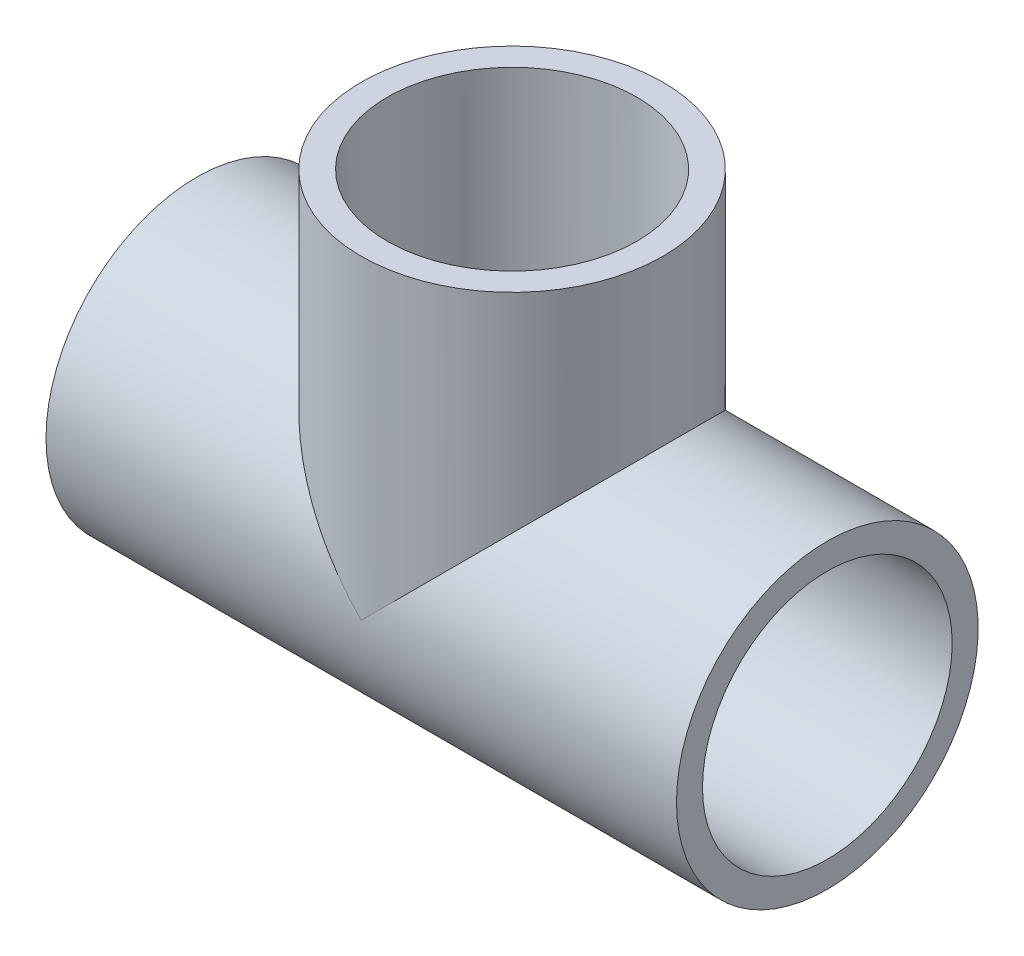
from build123d import *

# Parameters (mm, degrees)
SKETCH4_R           = 20.3327
BOSS_EXTRUDE1_DEPTH = 34.9504
SKETCH5_R           = 20.3327
BOSS_EXTRUDE2_DEPTH = 17.4752


with BuildPart() as part:
    # Sketch1 → Revolve1 (revolve)
    with BuildSketch(Plane.XY):
        Polygon((-42.4942, -20.3327), (-17.4752, -20.3327), (-17.4752, -16.637), (-42.4942, -16.8275), align=None)
        Polygon((42.4942, -16.8275), (17.4752, -16.637), (17.4752, -20.3327), (42.4942, -20.3327), align=None)
    revolve(axis=Axis((-42.4942, 0, 0), (1, 0, 0)))



with BuildPart() as body_2:
    # Sketch2 → Revolve2 (revolve)
    with BuildSketch(Plane.XY):
        Polygon((16.8275, 42.4942), (16.637, 17.4752), (20.3327, 17.4752), (20.3327, 42.4942), align=None)
    revolve(axis=Axis((0, 0, 0), (0, 1, 0)))


with BuildPart() as part_1:
    add(part.part)

    add(body_2.part)  # Boss-Extrude1 merges body 2
    # Sketch4 → Boss-Extrude1 (add)
    with BuildSketch(Plane(origin=(-17.4752, 0, 0), x_dir=(0, 0, -1), z_dir=(1, 0, 0))):
        Circle(SKETCH4_R)
    extrude(amount=BOSS_EXTRUDE1_DEPTH)

    # Sketch5 → Boss-Extrude2 (add)
    with BuildSketch(Plane.XZ.offset(-17.4752)):
        Circle(SKETCH5_R)
    extrude(amount=BOSS_EXTRUDE2_DEPTH)

    # Sketch6 → Cut-Revolve1 (revolve, cut)
    with BuildSketch(Plane.XY):
        Polygon((-42.4942, -16.8275), (-17.4752, -16.637), (-17.4752, -13.3223), (17.4752, -13.3223), (17.4752, -16.637), (42.4942, -16.8275), (42.4942, 0), (-42.4942, 0), align=None)
    revolve(axis=Axis((42.4942, 0, 0), (-1, 0, 0)), mode=Mode.SUBTRACT)

    # Sketch7 → Cut-Revolve2 (revolve, cut)
    with BuildSketch(Plane.XY):
        Polygon((16.8275, 42.4942), (16.637, 17.4752), (13.3223, 17.4752), (13.3223, 0), (0, 0), (0, 42.4942), align=None)
    revolve(axis=Axis((0, 0, 0), (0, 1, 0)), mode=Mode.SUBTRACT)


solid = part_1.part
